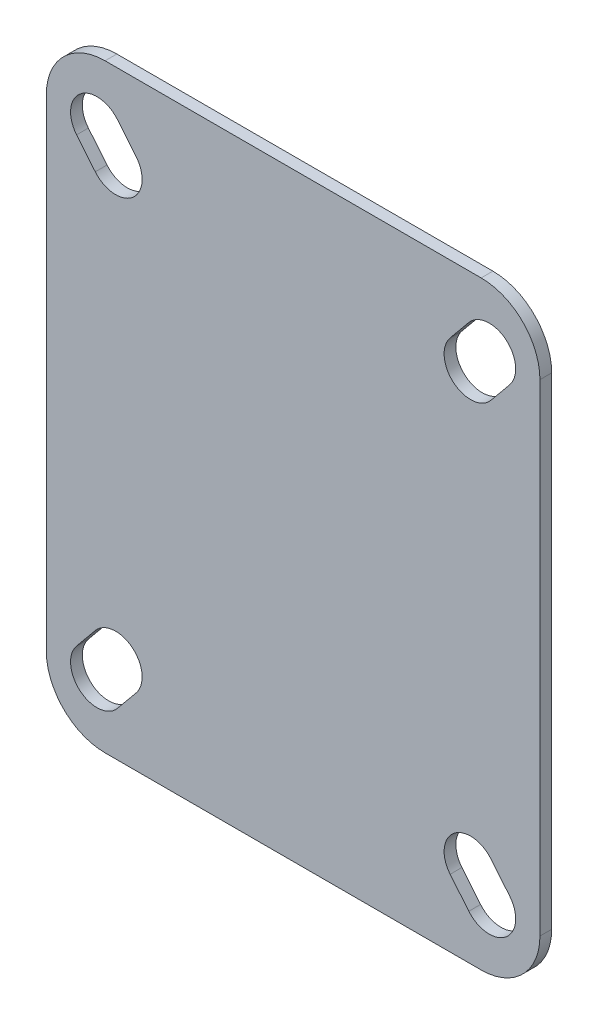
from build123d import *

# Parameters (mm, degrees)
SKETCH_1_R      = 27.5
EXTRUDE_1_DEPTH = 6
EXTRUDE_1_TAPER = -16
EXTRUDE_2_DEPTH = 2


with BuildPart() as part:
    # Эскиз1 → Бобышка-Вытянуть1 (new body)
    with BuildSketch(Plane.XY):
        with Locations((0, 27.755280905)):
            Circle(SKETCH_1_R)
    extrude(amount=EXTRUDE_1_DEPTH, taper=EXTRUDE_1_TAPER)

    # Эскиз3 → Бобышка-Вытянуть2 (add)
    with BuildSketch(Plane.XY.offset(6)):
        with BuildLine():
            Line((-32, 78.755280905), (32, 78.755280905))
            ThreePointArc((32, 78.755280905), (39.071067812, 75.826348716), (42, 68.755280905))
            Line((42, 68.755280905), (42, -13.244719095))
            ThreePointArc((42, -13.244719095), (39.071067812, -20.315786907), (32, -23.244719095))
            Line((32, -23.244719095), (-32, -23.244719095))
            ThreePointArc((-32, -23.244719095), (-39.071067812, -20.315786907), (-42, -13.244719095))
            Line((-42, -13.244719095), (-42, 68.755280905))
            ThreePointArc((-42, 68.755280905), (-39.071067812, 75.826348716), (-32, 78.755280905))
        make_face()
        with BuildLine():
            Line((-29.900944715, 71.142300912), (-26.722408451, 67.282649734))
            ThreePointArc((-26.722408451, 67.282649734), (-27.335411873, 60.948281036), (-33.669780571, 61.561284458))
            Line((-33.669780571, 61.561284458), (-36.848316835, 65.420935637))
            ThreePointArc((-36.848316835, 65.420935637), (-36.235313413, 71.755304335), (-29.900944715, 71.142300912))
        make_face(mode=Mode.SUBTRACT)
        with BuildLine():
            Line((36.848316835, 65.420935637), (33.669780571, 61.561284458))
            ThreePointArc((33.669780571, 61.561284458), (27.335411873, 60.948281036), (26.722408451, 67.282649734))
            Line((26.722408451, 67.282649734), (29.900944715, 71.142300912))
            ThreePointArc((29.900944715, 71.142300912), (36.235313413, 71.755304335), (36.848316835, 65.420935637))
        make_face(mode=Mode.SUBTRACT)
        with BuildLine():
            Line((29.900944715, -15.631739103), (26.722408451, -11.772087925))
            ThreePointArc((26.722408451, -11.772087925), (27.335411873, -5.437719227), (33.669780571, -6.050722649))
            Line((33.669780571, -6.050722649), (36.848316835, -9.910373827))
            ThreePointArc((36.848316835, -9.910373827), (36.235313413, -16.244742526), (29.900944715, -15.631739103))
        make_face(mode=Mode.SUBTRACT)
        with BuildLine():
            Line((-36.848316835, -9.910373827), (-33.669780571, -6.050722649))
            ThreePointArc((-33.669780571, -6.050722649), (-27.335411873, -5.437719227), (-26.722408451, -11.772087925))
            Line((-26.722408451, -11.772087925), (-29.900944715, -15.631739103))
            ThreePointArc((-29.900944715, -15.631739103), (-36.235313413, -16.244742526), (-36.848316835, -9.910373827))
        make_face(mode=Mode.SUBTRACT)
    extrude(amount=EXTRUDE_2_DEPTH)


solid = part.part
